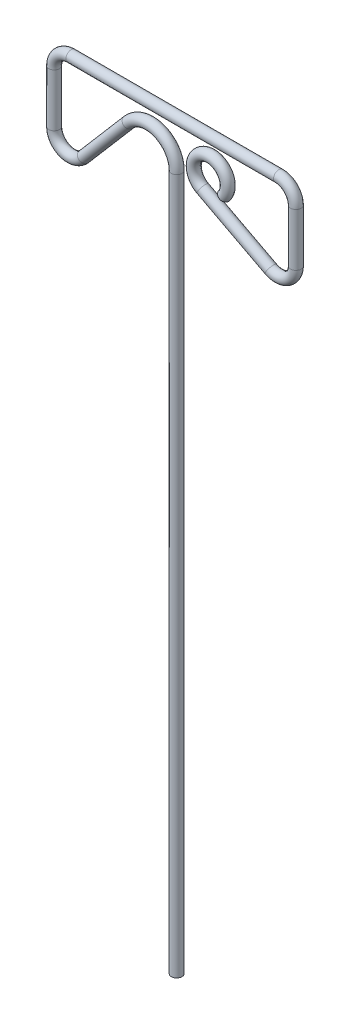
from build123d import *

# Parameters (mm, degrees)
SKETCH2_R = 0.78


with BuildPart() as part:
    # Sweep2: sweep along a path in Sketch1
    with BuildLine(Plane.XY) as sweep2_path:
        Line((0, 0), (0, 102.186970362))
        ThreePointArc((0, 102.186970362), (-2.612215009, 105.938510421), (-7.037026409, 104.790135856))
        Line((-7.037026409, 104.790135856), (-13.601858494, 97.13116509))
        ThreePointArc((-13.601858494, 97.13116509), (-16.367365619, 96.413430987), (-18, 98.758143524))
        Line((-18, 98.758143524), (-18, 106.5))
        ThreePointArc((-18, 106.5), (-17.267766953, 108.267766953), (-15.5, 109))
        Line((-15.5, 109), (15, 109))
        ThreePointArc((15, 109), (16.767766953, 108.267766953), (17.5, 106.5))
        Line((17.5, 106.5), (17.5, 98.758143524))
        ThreePointArc((17.5, 98.758143524), (16.293893855, 96.619022515), (13.839329047, 96.543907101))
        Line((13.839329047, 96.543907101), (3.839329047, 101.785763577))
        ThreePointArc((3.839329047, 101.785763577), (4.448953968, 106.438513537), (7, 102.5))
    # Sketch2 → Sweep2 (sweep)
    with BuildSketch(Plane(origin=(0, 0, 0), x_dir=(1, 0, 0), z_dir=(0, 1, 0))):
        Circle(SKETCH2_R)
    sweep(path=sweep2_path.line)


solid = part.part
